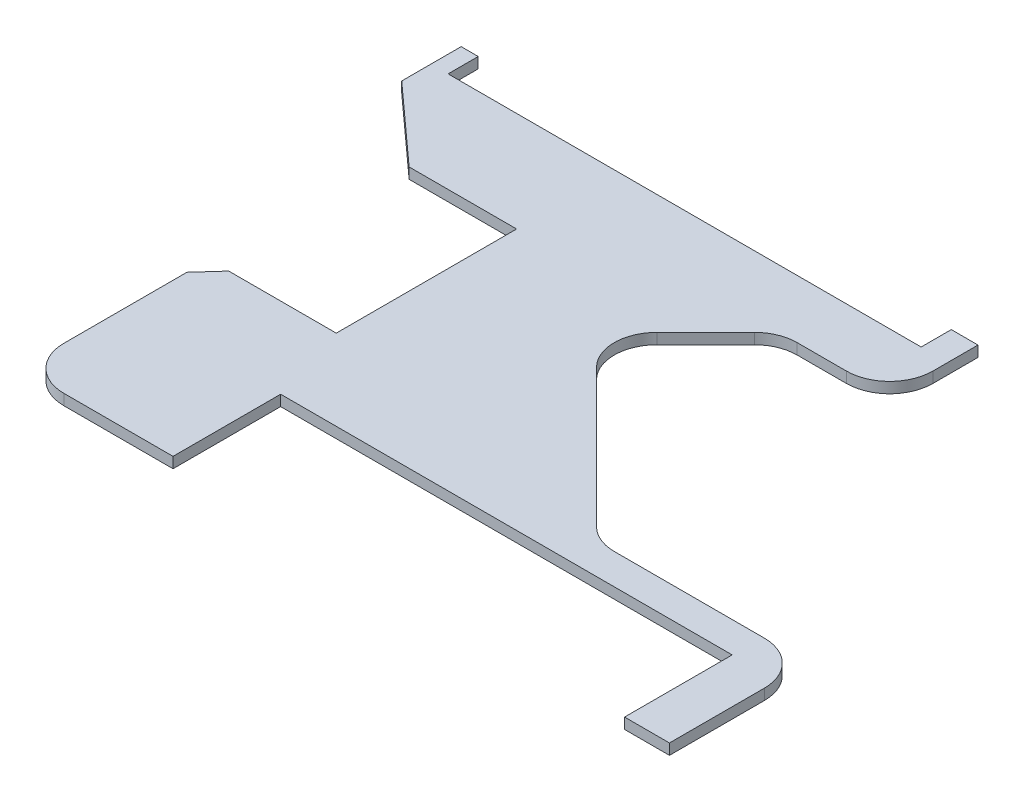
from build123d import *

# Parameters (mm, degrees)
BOSS_EXTRUDE1_DEPTH = 6.35


with BuildPart() as part:
    # Sketch2 → Boss-Extrude1 (new body)
    with BuildSketch(Plane(origin=(0, 0, 0), x_dir=(1, 0, 0), z_dir=(0, 1, 0))):
        with BuildLine():
            Line((-25.273, -79.248), (-25.273, -142.748))
            Line((-25.273, -142.748), (-89.721716587, -142.748))
            ThreePointArc((-89.721716587, -142.748), (-107.772031391, -135.271314803), (-115.248716587, -117.221))
            Line((-115.248716587, -117.221), (-115.248716587, -44.590319773))
            Line((-115.248716587, -44.590319773), (-103.51054261, -31.623))
            Line((-103.51054261, -31.623), (-40.0812, -31.623))
            Line((-40.0812, -31.623), (-40.0812, 0))
            Line((-40.0812, 0), (-40.0812, 74.803))
            Line((-40.0812, 74.803), (-103.503143824, 74.803))
            Line((-103.503143824, 74.803), (-149.633756095, 116.560985613))
            Line((-149.633756095, 116.560985613), (-149.633756095, 151.638))
            Line((-149.633756095, 151.638), (-139.573, 151.638))
            Line((-139.573, 151.638), (-139.573, 133.858))
            Line((-139.573, 133.858), (0, 133.858))
            Line((0, 133.858), (139.573, 133.858))
            Line((139.573, 133.858), (139.573, 151.638))
            Line((139.573, 151.638), (155.334898669, 151.638))
            Line((155.334898669, 151.638), (155.334898669, 125.037492411))
            ThreePointArc((155.334898669, 125.037492411), (147.858213472, 106.987177608), (129.807898669, 99.510492411))
            Line((129.807898669, 99.510492411), (100.730063349, 99.510492411))
            ThreePointArc((100.730063349, 99.510492411), (91.058504963, 97.586699836), (82.859353668, 92.108202092))
            Line((82.859353668, 92.108202092), (54.18030231, 63.429150734))
            ThreePointArc((54.18030231, 63.429150734), (46.778011991, 45.558441053), (54.18030231, 27.687731372))
            Line((54.18030231, 27.687731372), (135.638427829, -53.770394147))
            ThreePointArc((135.638427829, -53.770394147), (143.837579124, -59.248891891), (153.50913751, -61.172684466))
            Line((153.50913751, -61.172684466), (242.125928412, -61.172684466))
            ThreePointArc((242.125928412, -61.172684466), (260.176243215, -68.649369662), (267.652928412, -86.699684466))
            Line((267.652928412, -86.699684466), (267.652928412, -142.748))
            Line((267.652928412, -142.748), (241.173, -142.748))
            Line((241.173, -142.748), (241.173, -79.248))
            Line((241.173, -79.248), (0, -79.248))
            Line((0, -79.248), (-25.273, -79.248))
        make_face()
    extrude(amount=BOSS_EXTRUDE1_DEPTH)


solid = part.part
